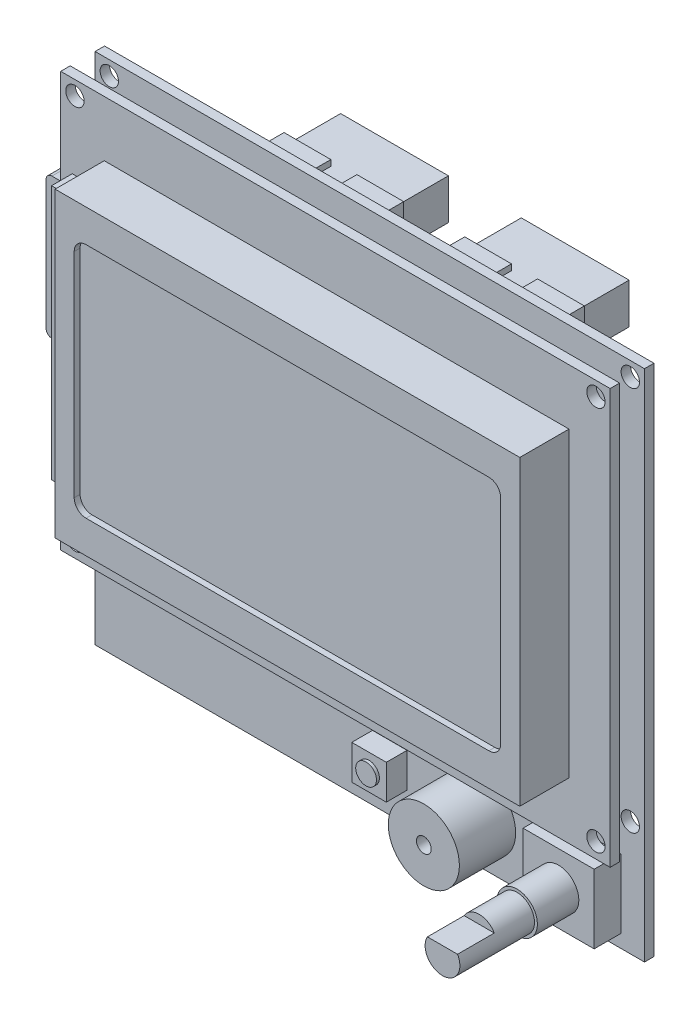
from build123d import *

# Parameters (mm, degrees)
SKETCH1_W                             = 92.75
SKETCH1_H                             = 86.75
SKETCH1_R                             = 1.55
BOSS_EXTRUDE1_FIRST_PCB_DEPTH         = 1.6
SKETCH2_R                             = 6
BOSS_EXTRUDE2_SPEAKER_DEPTH           = 9.5
SKETCH15_R                            = 1.25
CUT_EXTRUDE1_SPEAKER_HOLE_DEPTH       = 5
SKETCH3_W                             = 12
SKETCH3_H                             = 11.65
BOSS_EXTRUDE3_ROTARY_SWITCH_DEPTH     = 4.5
SKETCH4_W                             = 5.83
SKETCH4_H                             = 5.83
BOSS_EXTRUDE4_RESET_SWITCH_DEPTH      = 3.5
SKETCH5_R                             = 1.75
BOSS_EXTRUDE5_RESET_BUTTON_DEPTH      = 0.5
SKETCH16_R                            = 3.415
BOSS_EXTRUDE6_ROTARY_SWITCH_DEPTH     = 7
SKETCH17_R                            = 2.935
BOSS_EXTRUDE7_ROTARY_SWITCH_DEPTH     = 6.4
BOSS_EXTRUDE8_ROTARY_SWITCH_DEPTH     = 6.2
BOSS_EXTRUDE9_SD_CARD_SLOT_DEPTH      = 3
SKETCH19_W                            = 50
SKETCH19_H                            = 2.5
BOSS_EXTRUDE10_CONNECTOR_DEPTH        = 4.2
SKETCH11_W                            = 92.75
SKETCH11_H                            = 70
SKETCH11_R                            = 1.55
BOSS_EXTRUDE11_UPPER_PCB_DEPTH        = 1.6
SKETCH12_W                            = 78.45
SKETCH12_H                            = 51
BOSS_EXTRUDE12_LCD_DEPTH              = 8.3
SKETCH24_W                            = 5.4
SKETCH24_H                            = 43
BOSS_EXTRUDE13_LCD_BUMPOUT_DEPTH      = 3.5
CUT_EXTRUDE2_SCREEN_RECESS_DEPTH      = 1
SKETCH21_W                            = 20.2
SKETCH21_H                            = 8.85
SKETCH21_W_2                          = 18.2
SKETCH21_H_2                          = 6.85
BOSS_EXTRUDE14_CONNECTORS_DEPTH       = 9
SKETCH22_W                            = 18.2
SKETCH22_H                            = 6.85
BOSS_EXTRUDE15_CONNECTOR_RECESS_DEPTH = 2.55
SKETCH23_W                            = 4.4
SKETCH23_H                            = 1
CUT_EXTRUDE3_CONNECTOR_NOTCH_DEPTH    = 6.45
SKETCH20_W                            = 2.153
SKETCH20_H                            = 23.75
BOSS_EXTRUDE16_SD_CARD_DEPTH          = 10.4
FILLET1_SD_CARD_R                     = 1
CROQUIS1_W                            = 18.2
CROQUIS1_H                            = 6.85
SALIENTE_EXTRUIR1_DEPTH               = 15


with BuildPart() as part:
    # Sketch1 → Boss-Extrude1 - First PCB (new body)
    with BuildSketch(Plane.XY):
        Rectangle(SKETCH1_W, SKETCH1_H)
        with Locations((-43.975, 40.975)):
            Circle(SKETCH1_R, mode=Mode.SUBTRACT)
        with Locations((43.975, 40.975)):
            Circle(SKETCH1_R, mode=Mode.SUBTRACT)
        with Locations((43.975, -24.025)):
            Circle(SKETCH1_R, mode=Mode.SUBTRACT)
        with Locations((-43.975, -24.025)):
            Circle(SKETCH1_R, mode=Mode.SUBTRACT)
    extrude(amount=BOSS_EXTRUDE1_FIRST_PCB_DEPTH)

    # Sketch2 → Boss-Extrude2 - Speaker (add)
    with BuildSketch(Plane.XY.offset(1.6)):
        with Locations((18.625, -35.375)):
            Circle(SKETCH2_R)
    extrude(amount=BOSS_EXTRUDE2_SPEAKER_DEPTH)

    # Sketch15 → Cut-Extrude1 - Speaker Hole (cut)
    with BuildSketch(Plane.XY.offset(11.1)):
        with Locations((18.625, -35.375)):
            Circle(SKETCH15_R)
    extrude(amount=-CUT_EXTRUDE1_SPEAKER_HOLE_DEPTH, mode=Mode.SUBTRACT)

    # Sketch3 → Boss-Extrude3 - Rotary Switch (add)
    with BuildSketch(Plane(origin=(0, 0, 1.6), x_dir=(-1, 0, 0), z_dir=(0, 0, 1))):
        with Locations((-36.375, 35.375)):
            Rectangle(SKETCH3_W, SKETCH3_H)
    extrude(amount=BOSS_EXTRUDE3_ROTARY_SWITCH_DEPTH)

    # Sketch4 → Boss-Extrude4 - Reset Switch (add)
    with BuildSketch(Plane(origin=(0, 0, 1.6), x_dir=(-1, 0, 0), z_dir=(0, 0, 1))):
        with Locations((-3.375, 35.375)):
            Rectangle(SKETCH4_W, SKETCH4_H)
    extrude(amount=BOSS_EXTRUDE4_RESET_SWITCH_DEPTH)

    # Sketch5 → Boss-Extrude5 - Reset Button (add)
    with BuildSketch(Plane(origin=(0, 0, 5.1), x_dir=(-1, 0, 0), z_dir=(0, 0, 1))):
        with Locations((-3.375, 35.375)):
            Circle(SKETCH5_R)
    extrude(amount=BOSS_EXTRUDE5_RESET_BUTTON_DEPTH)

    # Sketch16 → Boss-Extrude6 - Rotary Switch (add)
    with BuildSketch(Plane.XY.offset(6.1)):
        with Locations((36.375, -35.375)):
            Circle(SKETCH16_R)
    extrude(amount=BOSS_EXTRUDE6_ROTARY_SWITCH_DEPTH)

    # Sketch17 → Boss-Extrude7 - Rotary Switch (add)
    with BuildSketch(Plane.XY.offset(13.1)):
        with Locations((36.375, -35.375)):
            Circle(SKETCH17_R)
    extrude(amount=BOSS_EXTRUDE7_ROTARY_SWITCH_DEPTH)

    # Sketch18 → Boss-Extrude8 - Rotary Switch (add)
    with BuildSketch(Plane.XY.offset(19.5)):
        with BuildLine():
            Line((33.831773703, -33.91), (38.918226297, -33.91))
            ThreePointArc((38.918226297, -33.91), (36.375, -38.31), (33.831773703, -33.91))
        make_face()
    extrude(amount=BOSS_EXTRUDE8_ROTARY_SWITCH_DEPTH)

    # Sketch9 → Boss-Extrude9 - SD Card Slot (add)
    with BuildSketch(Plane(origin=(0, 0, 0), x_dir=(1, 0, 0), z_dir=(0, 0, -1))):
        Polygon((-46.125, 5.425), (-27.875, 5.425), (-25.875, 3.425), (-20.375, 3.425), (-20.375, -20.975), (-46.125, -20.975), align=None)
    extrude(amount=BOSS_EXTRUDE9_SD_CARD_SLOT_DEPTH)

    # Sketch19 → Boss-Extrude10 - Connector (add)
    with BuildSketch(Plane.XY.offset(1.6)):
        with Locations((-8.375, -24.125)):
            Rectangle(SKETCH19_W, SKETCH19_H)
    extrude(amount=BOSS_EXTRUDE10_CONNECTOR_DEPTH)

    # Sketch11 → Boss-Extrude11 - Upper PCB (add)
    with BuildSketch(Plane(origin=(0, -2, 5.8), x_dir=(1, 0, 0), z_dir=(0, 0, -1))):
        with Locations((0, -10.375)):
            Rectangle(SKETCH11_W, SKETCH11_H)
        with Locations((-43.975, -42.975)):
            Circle(SKETCH11_R, mode=Mode.SUBTRACT)
        with Locations((-43.975, 22.025)):
            Circle(SKETCH11_R, mode=Mode.SUBTRACT)
        with Locations((43.975, -42.975)):
            Circle(SKETCH11_R, mode=Mode.SUBTRACT)
        with Locations((43.975, 22.025)):
            Circle(SKETCH11_R, mode=Mode.SUBTRACT)
    extrude(amount=-BOSS_EXTRUDE11_UPPER_PCB_DEPTH)

    # Sketch12 → Boss-Extrude12 - LCD (add)
    with BuildSketch(Plane(origin=(0, 0, 7.4), x_dir=(-1, 0, 0), z_dir=(0, 0, 1))):
        with Locations((-0.2, -8.475)):
            Rectangle(SKETCH12_W, SKETCH12_H)
    extrude(amount=BOSS_EXTRUDE12_LCD_DEPTH)

    # Sketch24 → Boss-Extrude13 - LCD Bumpout (add)
    with BuildSketch(Plane.XY.offset(7.4)):
        with Locations((-41.725, 7.875)):
            Rectangle(SKETCH24_W, SKETCH24_H)
    extrude(amount=BOSS_EXTRUDE13_LCD_BUMPOUT_DEPTH)

    # Sketch13 → Cut-Extrude2 - Screen Recess (cut)
    with BuildSketch(Plane(origin=(0, 0, 15.7), x_dir=(-1, 0, 0), z_dir=(0, 0, 1))):
        with BuildLine():
            Line((-34.2, 11.525), (33.8, 11.525))
            ThreePointArc((33.8, 11.525), (35.214213562, 10.939213562), (35.8, 9.525))
            Line((35.8, 9.525), (35.8, -26.475))
            ThreePointArc((35.8, -26.475), (35.214213562, -27.889213562), (33.8, -28.475))
            Line((33.8, -28.475), (-34.2, -28.475))
            ThreePointArc((-34.2, -28.475), (-35.614213562, -27.889213562), (-36.2, -26.475))
            Line((-36.2, -26.475), (-36.2, 9.525))
            ThreePointArc((-36.2, 9.525), (-35.614213562, 10.939213562), (-34.2, 11.525))
        make_face()
    extrude(amount=-CUT_EXTRUDE2_SCREEN_RECESS_DEPTH, mode=Mode.SUBTRACT)

    # Sketch21 → Boss-Extrude14 - Connectors (add)
    with BuildSketch(Plane(origin=(0, 0, 0), x_dir=(-1, 0, 0), z_dir=(0, 0, -1))):
        with Locations((-15.525, 32.45)):
            Rectangle(SKETCH21_W, SKETCH21_H)
        with Locations((-15.525, 32.45)):
            Rectangle(SKETCH21_W_2, SKETCH21_H_2, mode=Mode.SUBTRACT)
        with Locations((14.975, 32.45)):
            Rectangle(SKETCH21_W, SKETCH21_H)
        with Locations((14.975, 32.45)):
            Rectangle(SKETCH21_W_2, SKETCH21_H_2, mode=Mode.SUBTRACT)
    extrude(amount=BOSS_EXTRUDE14_CONNECTORS_DEPTH)

    # Sketch22 → Boss-Extrude15 - Connector Recess (add)
    with BuildSketch(Plane(origin=(0, 0, 0), x_dir=(-1, 0, 0), z_dir=(0, 0, -1))):
        with Locations((-15.525, 32.45)):
            Rectangle(SKETCH22_W, SKETCH22_H)
        with Locations((14.975, 32.45)):
            Rectangle(SKETCH22_W, SKETCH22_H)
    extrude(amount=BOSS_EXTRUDE15_CONNECTOR_RECESS_DEPTH)

    # Sketch23 → Cut-Extrude3 - Connector Notch (cut)
    with BuildSketch(Plane(origin=(0, 0, -9), x_dir=(-1, 0, 0), z_dir=(0, 0, -1))):
        with Locations((-15.525, 36.375)):
            Rectangle(SKETCH23_W, SKETCH23_H)
        with Locations((14.975, 36.375)):
            Rectangle(SKETCH23_W, SKETCH23_H)
    extrude(amount=-CUT_EXTRUDE3_CONNECTOR_NOTCH_DEPTH, mode=Mode.SUBTRACT)

    # Sketch20 → Boss-Extrude16 - SD Card (add)
    with BuildSketch(Plane.ZY.offset(46.125)):
        with Locations((-1.3465, 7.775)):
            Rectangle(SKETCH20_W, SKETCH20_H)
    extrude(amount=BOSS_EXTRUDE16_SD_CARD_DEPTH)

    # Fillet1 - SD Card
    fillet1_sd_card_edges = [part.edges().sort_by_distance(p)[0] for p in [
        (-56.525, -4.1, -1.3465),
        (-56.525, 19.65, -1.3465),
    ]]
    fillet(fillet1_sd_card_edges, radius=FILLET1_SD_CARD_R)

    # Croquis1 → Saliente-Extruir1 (add)
    with BuildSketch(Plane(origin=(0, 0, -2.55), x_dir=(-1, 0, 0), z_dir=(0, 0, -1))):
        with Locations((-15.525, 32.45)):
            Rectangle(CROQUIS1_W, CROQUIS1_H)
        with Locations((14.975, 32.45)):
            Rectangle(CROQUIS1_W, CROQUIS1_H)
    extrude(amount=SALIENTE_EXTRUIR1_DEPTH)


solid = part.part
